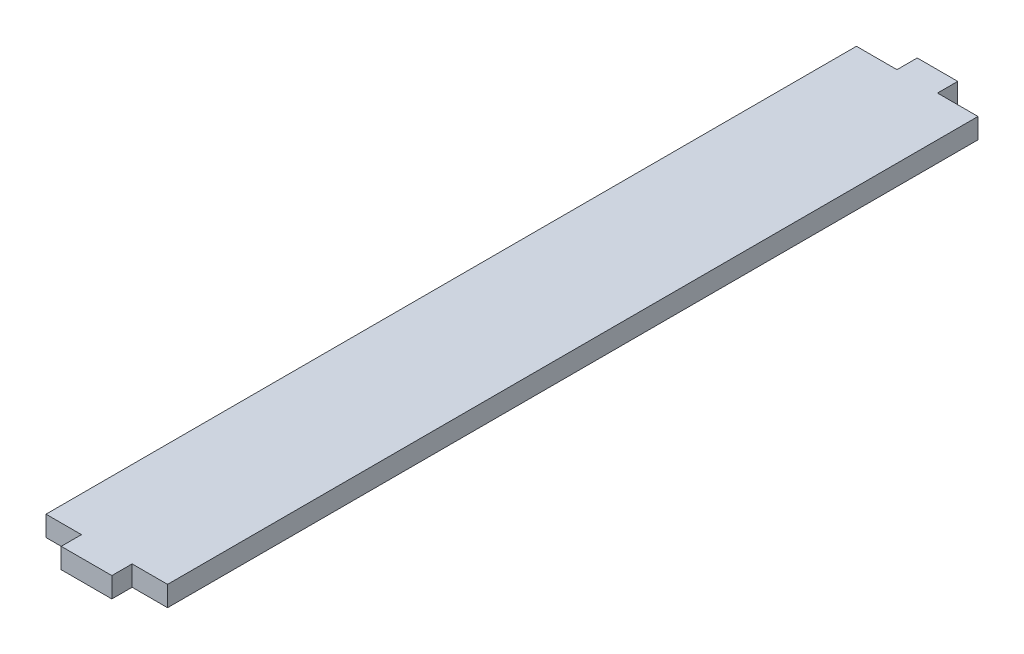
from build123d import *

# Parameters (mm, degrees)
SKETCH1_W           = 12.5
SKETCH1_H           = 10
SKETCH1_W_2         = 30
SKETCH1_H_2         = 200
SKETCH1_W_3         = 10
BOSS_EXTRUDE1_DEPTH = 5


with BuildPart() as part:
    # Sketch1 → Boss-Extrude1 (new body)
    with BuildSketch(Plane(origin=(0, 0, 0), x_dir=(1, 0, 0), z_dir=(0, 1, 0))):
        with Locations((83.16678375, -31.56250034)):
            Rectangle(SKETCH1_W, SKETCH1_H)
        with Locations((83.16678375, 68.43749966)):
            Rectangle(SKETCH1_W_2, SKETCH1_H_2)
        with Locations((83.16678375, 168.43749966)):
            Rectangle(SKETCH1_W_3, SKETCH1_H)
    extrude(amount=BOSS_EXTRUDE1_DEPTH)


solid = part.part
